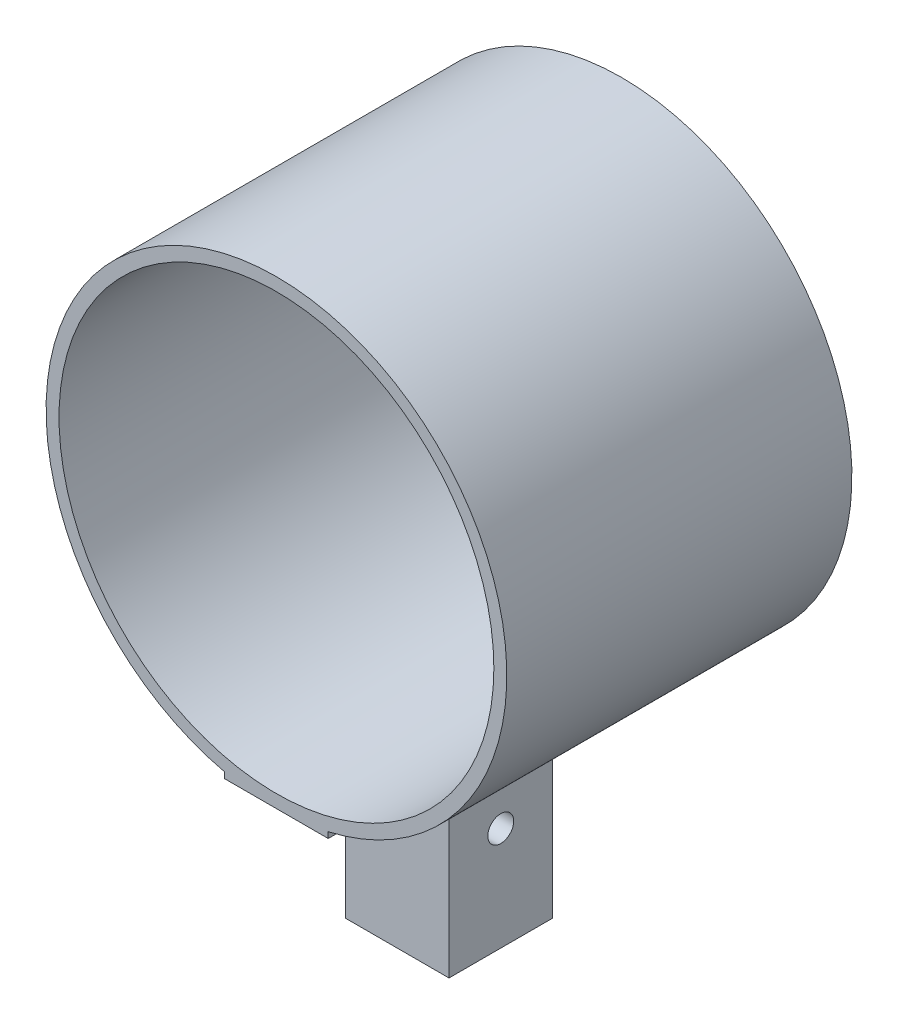
from build123d import *

# Parameters (mm, degrees)
BOSS_EXTRUDE1_DEPTH = 84.666666667
SKETCH2_R           = 53.34
CUT_EXTRUDE1_DEPTH  = 85.666666667
SKETCH3_W           = 25.4
SKETCH3_H           = 25.4
BOSS_EXTRUDE2_DEPTH = 44.45
SKETCH5_R           = 3.175
CUT_EXTRUDE2_DEPTH  = 70.215


with BuildPart() as part:
    # Sketch1 → Boss-Extrude1 (new body)
    with BuildSketch(Plane.XY):
        with BuildLine():
            Line((-12.7, -56.515), (12.7, -56.515))
            Line((12.7, -56.515), (12.7, -55.069548981))
            ThreePointArc((12.7, -55.069548981), (0, 56.515), (-12.7, -55.069548981))
            Line((-12.7, -55.069548981), (-12.7, -56.515))
        make_face()
    extrude(amount=BOSS_EXTRUDE1_DEPTH)

    # Sketch2 → Cut-Extrude1 (cut, through all)
    with BuildSketch(Plane.XY.offset(84.666666667)):
        Circle(SKETCH2_R)
    extrude(amount=-CUT_EXTRUDE1_DEPTH, mode=Mode.SUBTRACT)

    # Sketch3 → Boss-Extrude2 (add)
    with BuildSketch(Plane.XZ.offset(56.515)):
        with Locations((0, 42.333333333)):
            Rectangle(SKETCH3_W, SKETCH3_H)
    extrude(amount=BOSS_EXTRUDE2_DEPTH)

    # Sketch5 → Cut-Extrude2 (cut, through all)
    with BuildSketch(Plane(origin=(12.7, 0, 0), x_dir=(0, 0, -1), z_dir=(1, 0, 0))):
        with Locations((-42.333333333, -75.565)):
            Circle(SKETCH5_R)
    extrude(amount=-CUT_EXTRUDE2_DEPTH, mode=Mode.SUBTRACT)


solid = part.part
